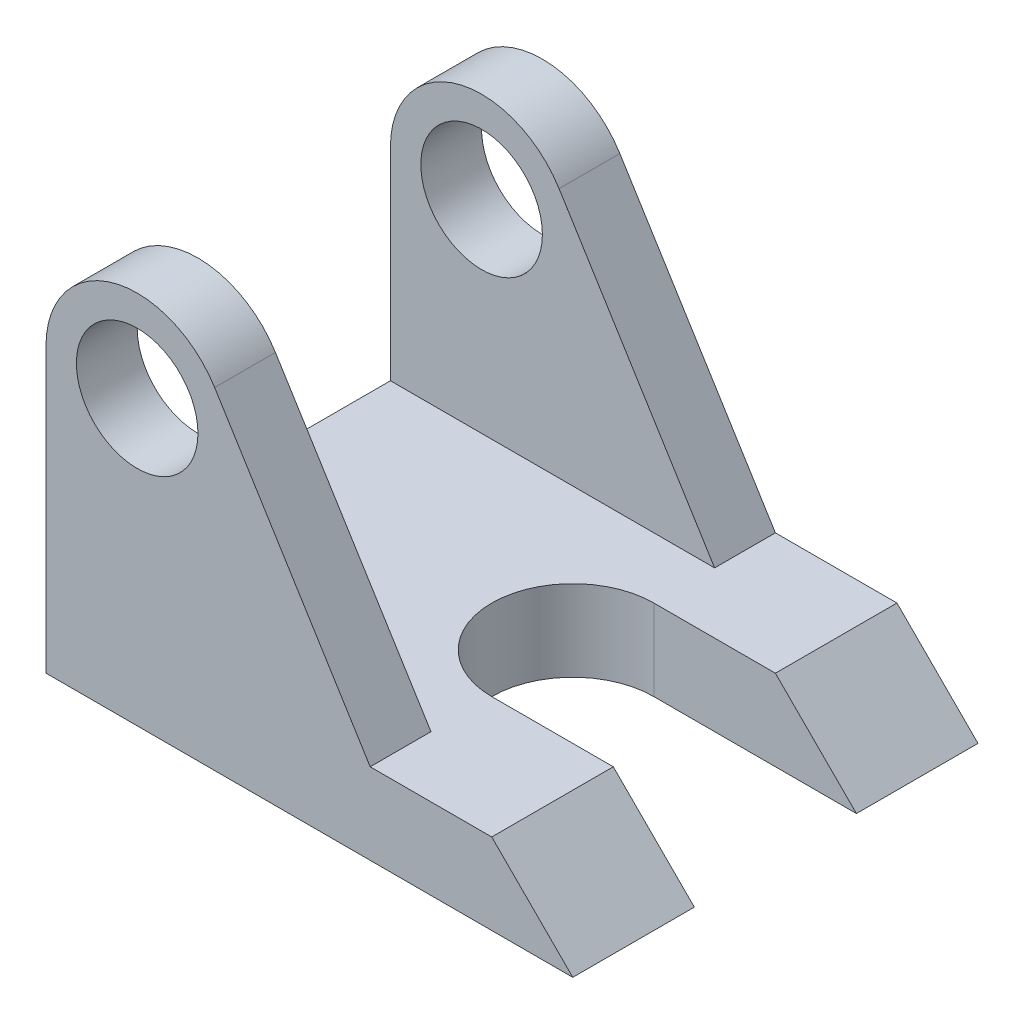
from build123d import *

# Parameters (mm, degrees)
SKETCH1_R           = 22.5
SKETCH1_R_2         = 15
BOSS_EXTRUDE1_DEPTH = 100
SKETCH2_W           = 167.207150193
SKETCH2_H           = 70
CUT_EXTRUDE1_DEPTH  = 73.5
CUT_EXTRUDE2_DEPTH  = 21


with BuildPart() as part:
    # Sketch1 → Boss-Extrude1 (new body)
    with BuildSketch(Plane.XY):
        with BuildLine():
            Line((0, 70), (0, 0))
            Line((0, 0), (130, 0))
            Line((130, 0), (110, 20))
            Line((110, 20), (80, 20))
            Line((80, 20), (41.61915802, 81.862031723))
            ThreePointArc((41.61915802, 81.862031723), (44.138288466, 76.16720944), (45, 70))
            ThreePointArc((45, 70), (22.5, 47.5), (0, 70))
        make_face()
        with Locations((22.5, 70)):
            Circle(SKETCH1_R)
        with Locations((22.5, 70)):
            Circle(SKETCH1_R_2, mode=Mode.SUBTRACT)
    extrude(amount=-BOSS_EXTRUDE1_DEPTH)

    # Sketch2 → Cut-Extrude1 (cut, through all)
    with BuildSketch(Plane(origin=(0, 20, 0), x_dir=(1, 0, 0), z_dir=(0, 1, 0))):
        with Locations((64.505889037, 50)):
            Rectangle(SKETCH2_W, SKETCH2_H)
    extrude(amount=CUT_EXTRUDE1_DEPTH, mode=Mode.SUBTRACT)

    # Sketch3 → Cut-Extrude2 (cut, through all)
    with BuildSketch(Plane(origin=(0, 20, 0), x_dir=(1, 0, 0), z_dir=(0, 1, 0))):
        with BuildLine():
            Line((80, 70), (130, 70))
            Line((130, 70), (130, 30))
            Line((130, 30), (80, 30))
            ThreePointArc((80, 30), (60, 50), (80, 70))
        make_face()
    extrude(amount=-CUT_EXTRUDE2_DEPTH, mode=Mode.SUBTRACT)


solid = part.part
